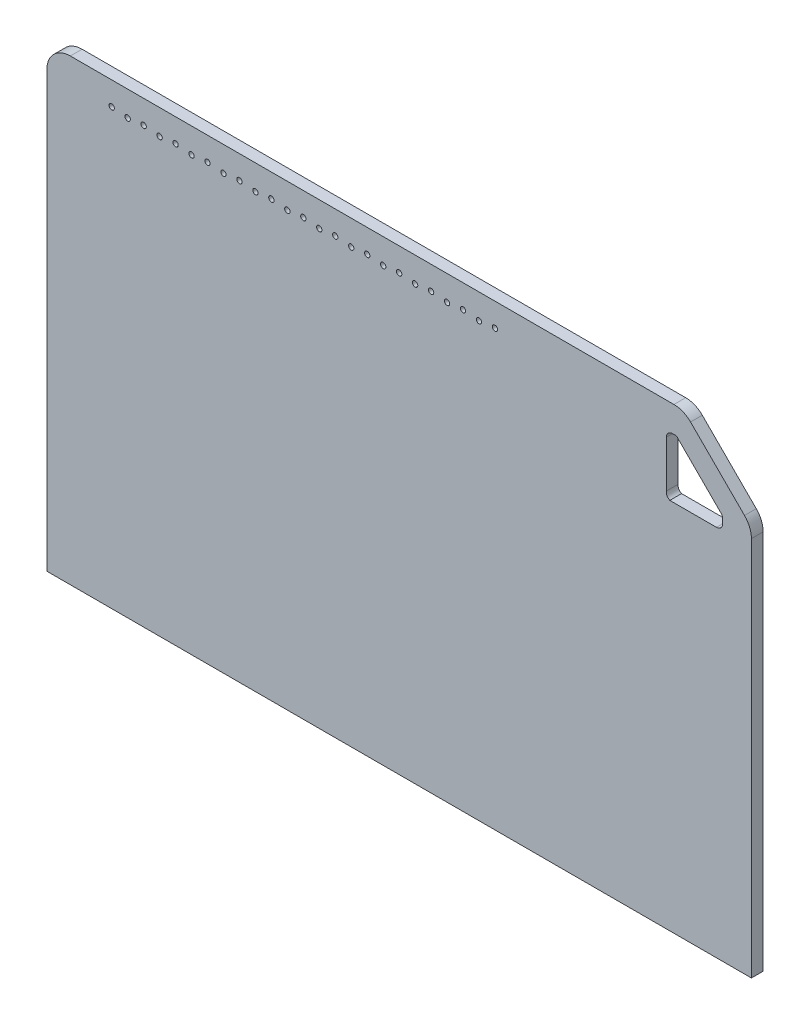
from build123d import *

# Parameters (mm, degrees)
LOWER_MPCHIP_R      = 12.7
BOSS_EXTRUDE1_DEPTH = 25.4
BOSS_EXTRUDE2_DEPTH = 25.4
CUT_EXTRUDE1_DEPTH  = 12.7
SKETCH12_R          = 5.78
CUT_EXTRUDE2_DEPTH  = 26.4
SKETCH13_W          = 3566.23722931
SKETCH13_H          = 1219.2
CUT_EXTRUDE3_DEPTH  = 26.4


with BuildPart() as part:
    # lower mpchip → Boss-Extrude1 (new body)
    with BuildSketch(Plane.XY):
        with BuildLine():
            Line((-762.201152263, -317.508408711), (761.798847737, -317.508408711))
            Line((761.798847737, -317.508408711), (761.798847737, -1480.956188545))
            ThreePointArc((761.798847737, -1480.956188545), (746.752491854, -1519.103697906), (709.716030721, -1536.708408711))
            Line((709.716030721, -1536.708408711), (-486.894749236, -1536.708408711))
            ThreePointArc((-486.894749236, -1536.708408711), (-506.3350676, -1532.841488963), (-522.815773721, -1521.829433195))
            Line((-522.815773721, -1521.829433195), (-747.322176747, -1297.323030169))
            ThreePointArc((-747.322176747, -1297.323030169), (-758.334232515, -1280.842324049), (-762.201152263, -1261.402005684))
            Line((-762.201152263, -1261.402005684), (-762.201152263, -573.5936))
            Line((-762.201152263, -573.5936), (-762.201152263, -317.508408711))
        make_face()
        with Locations((-621.20176, -630.088)):
            Circle(LOWER_MPCHIP_R, mode=Mode.SUBTRACT)
        with Locations((-414.14176, -630.088)):
            Circle(LOWER_MPCHIP_R, mode=Mode.SUBTRACT)
        with Locations((-208.08, -656.064)):
            Circle(LOWER_MPCHIP_R, mode=Mode.SUBTRACT)
        with Locations((-70.04, -656.064)):
            Circle(LOWER_MPCHIP_R, mode=Mode.SUBTRACT)
        with Locations((68, -656.064)):
            Circle(LOWER_MPCHIP_R, mode=Mode.SUBTRACT)
        with Locations((206.04, -656.064)):
            Circle(LOWER_MPCHIP_R, mode=Mode.SUBTRACT)
        with Locations((344.08, -656.064)):
            Circle(LOWER_MPCHIP_R, mode=Mode.SUBTRACT)
        with Locations((482.12, -656.064)):
            Circle(LOWER_MPCHIP_R, mode=Mode.SUBTRACT)
        with Locations((632.264, -656.064)):
            Circle(LOWER_MPCHIP_R, mode=Mode.SUBTRACT)
        with Locations((552.13824, -768.944)):
            Circle(LOWER_MPCHIP_R, mode=Mode.SUBTRACT)
        with Locations((414.09824, -768.944)):
            Circle(LOWER_MPCHIP_R, mode=Mode.SUBTRACT)
        with Locations((276.05824, -768.944)):
            Circle(LOWER_MPCHIP_R, mode=Mode.SUBTRACT)
        with Locations((138.01824, -768.944)):
            Circle(LOWER_MPCHIP_R, mode=Mode.SUBTRACT)
        with Locations((-0.02176, -768.944)):
            Circle(LOWER_MPCHIP_R, mode=Mode.SUBTRACT)
        with Locations((-138.06176, -768.944)):
            Circle(LOWER_MPCHIP_R, mode=Mode.SUBTRACT)
        with Locations((-331.99776, -712.232)):
            Circle(LOWER_MPCHIP_R, mode=Mode.SUBTRACT)
        with Locations((-414.14176, -794.376)):
            Circle(LOWER_MPCHIP_R, mode=Mode.SUBTRACT)
        with Locations((-496.28576, -712.232)):
            Circle(LOWER_MPCHIP_R, mode=Mode.SUBTRACT)
        with Locations((-621.20176, -909.16)):
            Circle(LOWER_MPCHIP_R, mode=Mode.SUBTRACT)
        with Locations((-483.16176, -909.16)):
            Circle(LOWER_MPCHIP_R, mode=Mode.SUBTRACT)
        with Locations((-345.12176, -909.16)):
            Circle(LOWER_MPCHIP_R, mode=Mode.SUBTRACT)
        with Locations((-207.08176, -909.16)):
            Circle(LOWER_MPCHIP_R, mode=Mode.SUBTRACT)
        with Locations((-69.04176, -909.16)):
            Circle(LOWER_MPCHIP_R, mode=Mode.SUBTRACT)
        with Locations((68.99824, -909.16)):
            Circle(LOWER_MPCHIP_R, mode=Mode.SUBTRACT)
        with Locations((207.03824, -909.16)):
            Circle(LOWER_MPCHIP_R, mode=Mode.SUBTRACT)
        with Locations((345.07824, -909.16)):
            Circle(LOWER_MPCHIP_R, mode=Mode.SUBTRACT)
        with Locations((483.11824, -909.16)):
            Circle(LOWER_MPCHIP_R, mode=Mode.SUBTRACT)
        with Locations((621.20176, -909.16)):
            Circle(LOWER_MPCHIP_R, mode=Mode.SUBTRACT)
        with Locations((552.20624, -1022.04)):
            Circle(LOWER_MPCHIP_R, mode=Mode.SUBTRACT)
        with Locations((632.264, -1134.92)):
            Circle(LOWER_MPCHIP_R, mode=Mode.SUBTRACT)
        with Locations((483.11824, -1134.92)):
            Circle(LOWER_MPCHIP_R, mode=Mode.SUBTRACT)
        with Locations((414.16624, -1022.04)):
            Circle(LOWER_MPCHIP_R, mode=Mode.SUBTRACT)
        with Locations((276.12624, -1022.04)):
            Circle(LOWER_MPCHIP_R, mode=Mode.SUBTRACT)
        with Locations((138.08624, -1022.04)):
            Circle(LOWER_MPCHIP_R, mode=Mode.SUBTRACT)
        with Locations((-0.04624, -1022.04)):
            Circle(LOWER_MPCHIP_R, mode=Mode.SUBTRACT)
        with Locations((-137.99376, -1022.04)):
            Circle(LOWER_MPCHIP_R, mode=Mode.SUBTRACT)
        with Locations((-276.03376, -1022.04)):
            Circle(LOWER_MPCHIP_R, mode=Mode.SUBTRACT)
        with Locations((-414.07376, -1022.04)):
            Circle(LOWER_MPCHIP_R, mode=Mode.SUBTRACT)
        with Locations((-552.11376, -1022.04)):
            Circle(LOWER_MPCHIP_R, mode=Mode.SUBTRACT)
        with Locations((-621.20176, -1134.92)):
            Circle(LOWER_MPCHIP_R, mode=Mode.SUBTRACT)
        with Locations((-483.16176, -1134.92)):
            Circle(LOWER_MPCHIP_R, mode=Mode.SUBTRACT)
        with Locations((-345.12176, -1134.92)):
            Circle(LOWER_MPCHIP_R, mode=Mode.SUBTRACT)
        with Locations((-207.08176, -1134.92)):
            Circle(LOWER_MPCHIP_R, mode=Mode.SUBTRACT)
        with Locations((-69.04176, -1134.92)):
            Circle(LOWER_MPCHIP_R, mode=Mode.SUBTRACT)
        with Locations((68.99824, -1134.92)):
            Circle(LOWER_MPCHIP_R, mode=Mode.SUBTRACT)
        with Locations((207.03824, -1134.92)):
            Circle(LOWER_MPCHIP_R, mode=Mode.SUBTRACT)
        with Locations((345.07824, -1134.92)):
            Circle(LOWER_MPCHIP_R, mode=Mode.SUBTRACT)
        with Locations((552.11376, -1247.8)):
            Circle(LOWER_MPCHIP_R, mode=Mode.SUBTRACT)
        with Locations((414.07376, -1247.8)):
            Circle(LOWER_MPCHIP_R, mode=Mode.SUBTRACT)
        with Locations((276.03376, -1247.8)):
            Circle(LOWER_MPCHIP_R, mode=Mode.SUBTRACT)
        with Locations((-276.03376, -1247.8)):
            Circle(LOWER_MPCHIP_R, mode=Mode.SUBTRACT)
        with Locations((-414.07376, -1247.8)):
            Circle(LOWER_MPCHIP_R, mode=Mode.SUBTRACT)
        with Locations((-552.11376, -1247.8)):
            Circle(LOWER_MPCHIP_R, mode=Mode.SUBTRACT)
        with Locations((-97.632449909, -1263.063884579)):
            Circle(LOWER_MPCHIP_R, mode=Mode.SUBTRACT)
        with Locations((106.666799165, -1262.352)):
            Circle(LOWER_MPCHIP_R, mode=Mode.SUBTRACT)
        with Locations((0.272, -1404.472)):
            Circle(LOWER_MPCHIP_R, mode=Mode.SUBTRACT)
        with BuildLine():
            Line((-538.8864, -1379.4208), (-538.8864, -1386.3296))
            ThreePointArc((-538.8864, -1386.3296), (-483.616, -1441.6), (-428.3456, -1386.3296))
            Line((-428.3456, -1386.3296), (-428.3456, -1379.4208))
            ThreePointArc((-428.3456, -1379.4208), (-483.616, -1324.1504), (-538.8864, -1379.4208))
        make_face(mode=Mode.SUBTRACT)
        Polygon((452.208145356, -1437.2752), (515.023854644, -1437.2752), (546.431709288, -1382.8752), (515.023854644, -1328.4752), (452.208145356, -1328.4752), (420.800290712, -1382.8752), align=None, mode=Mode.SUBTRACT)
    extrude(amount=BOSS_EXTRUDE1_DEPTH)

    # Sketch5 → Boss-Extrude2 (add)
    with BuildSketch(Plane.XY):
        with BuildLine():
            Line((761.798847737, -317.508408711), (-762.201152263, -317.508408711))
            Line((-762.201152263, -317.508408711), (-762.201152263, 622.324930397))
            ThreePointArc((-762.201152263, 622.324930397), (-747.322176747, 658.245954881), (-711.401152263, 673.124930397))
            Line((-711.401152263, 673.124930397), (594.255518163, 673.124930397))
            ThreePointArc((594.255518163, 673.124930397), (613.695836527, 669.258010649), (630.176542647, 658.245954881))
            Line((630.176542647, 658.245954881), (746.919872221, 541.502625308))
            ThreePointArc((746.919872221, 541.502625308), (757.931927989, 525.021919187), (761.798847737, 505.581600823))
            Line((761.798847737, 505.581600823), (761.798847737, 68.063364259))
            Line((761.798847737, 68.063364259), (761.798847737, -317.508408711))
        make_face()
        with BuildLine():
            Line((585.298918243, 488.974930397), (686.183718243, 488.974930397))
            ThreePointArc((686.183718243, 488.974930397), (695.800370467, 492.958278173), (699.783718243, 502.574930397))
            Line((699.783718243, 502.574930397), (699.783718243, 510.541625949))
            ThreePointArc((699.783718243, 510.541625949), (698.895409188, 516.020679535), (695.891961756, 520.688486804))
            Line((695.891961756, 520.688486804), (602.973857308, 613.606591252))
            ThreePointArc((602.973857308, 613.606591252), (601.251852502, 615.463066183), (599.215543289, 616.968139108))
            Line((599.215543289, 616.968139108), (591.248847737, 616.968139108))
            ThreePointArc((591.248847737, 616.968139108), (581.632195513, 612.984791332), (577.648847737, 603.368139108))
            Line((577.648847737, 603.368139108), (577.648847737, 502.483339108))
            ThreePointArc((577.648847737, 502.483339108), (579.357112847, 494.53036729), (585.298918243, 488.974930397))
        make_face(mode=Mode.SUBTRACT)
    extrude(amount=BOSS_EXTRUDE2_DEPTH)

    # Sketch6 → Cut-Extrude1 (cut)
    with BuildSketch(Plane.XY.offset(25.4)):
        with BuildLine():
            ThreePointArc((4.331497575, -1447.460752941), (43.452, -1404.472), (4.331497575, -1361.483247059))
            ThreePointArc((4.331497575, -1361.483247059), (0.272, -1357.228), (-3.787497575, -1361.483247059))
            ThreePointArc((-3.787497575, -1361.483247059), (-42.908, -1404.472), (-3.787497575, -1447.460752941))
            ThreePointArc((-3.787497575, -1447.460752941), (0.272, -1451.716), (4.331497575, -1447.460752941))
        make_face()
        with BuildLine():
            ThreePointArc((110.72629674, -1305.340752941), (149.846799165, -1262.352), (110.72629674, -1219.363247059))
            ThreePointArc((110.72629674, -1219.363247059), (106.666799165, -1215.108), (102.60730159, -1219.363247059))
            ThreePointArc((102.60730159, -1219.363247059), (63.486799165, -1262.352), (102.60730159, -1305.340752941))
            ThreePointArc((102.60730159, -1305.340752941), (106.666799165, -1309.596), (110.72629674, -1305.340752941))
        make_face()
        with BuildLine():
            ThreePointArc((280.093257575, -1290.788752941), (319.21376, -1247.8), (280.093257575, -1204.811247059))
            ThreePointArc((280.093257575, -1204.811247059), (276.03376, -1200.556), (271.974262425, -1204.811247059))
            ThreePointArc((271.974262425, -1204.811247059), (232.85376, -1247.8), (271.974262425, -1290.788752941))
            ThreePointArc((271.974262425, -1290.788752941), (276.03376, -1295.044), (280.093257575, -1290.788752941))
        make_face()
        with BuildLine():
            ThreePointArc((-93.572952334, -1306.05263752), (-54.452449909, -1263.063884579), (-93.572952334, -1220.075131637))
            ThreePointArc((-93.572952334, -1220.075131637), (-97.632449909, -1215.819884579), (-101.691947484, -1220.075131637))
            ThreePointArc((-101.691947484, -1220.075131637), (-140.812449909, -1263.063884579), (-101.691947484, -1306.05263752))
            ThreePointArc((-101.691947484, -1306.05263752), (-97.632449909, -1310.307884579), (-93.572952334, -1306.05263752))
        make_face()
        with BuildLine():
            ThreePointArc((-271.974262425, -1290.788752941), (-232.85376, -1247.8), (-271.974262425, -1204.811247059))
            ThreePointArc((-271.974262425, -1204.811247059), (-276.03376, -1200.556), (-280.093257575, -1204.811247059))
            ThreePointArc((-280.093257575, -1204.811247059), (-319.21376, -1247.8), (-280.093257575, -1290.788752941))
            ThreePointArc((-280.093257575, -1290.788752941), (-276.03376, -1295.044), (-271.974262425, -1290.788752941))
        make_face()
        with BuildLine():
            ThreePointArc((-410.014262425, -1290.788752941), (-370.89376, -1247.8), (-410.014262425, -1204.811247059))
            ThreePointArc((-410.014262425, -1204.811247059), (-414.07376, -1200.556), (-418.133257575, -1204.811247059))
            ThreePointArc((-418.133257575, -1204.811247059), (-457.25376, -1247.8), (-418.133257575, -1290.788752941))
            ThreePointArc((-418.133257575, -1290.788752941), (-414.07376, -1295.044), (-410.014262425, -1290.788752941))
        make_face()
        with BuildLine():
            ThreePointArc((-341.062262425, -1177.908752941), (-301.94176, -1134.92), (-341.062262425, -1091.931247059))
            ThreePointArc((-341.062262425, -1091.931247059), (-345.12176, -1087.676), (-349.181257575, -1091.931247059))
            ThreePointArc((-349.181257575, -1091.931247059), (-388.30176, -1134.92), (-349.181257575, -1177.908752941))
            ThreePointArc((-349.181257575, -1177.908752941), (-345.12176, -1182.164), (-341.062262425, -1177.908752941))
        make_face()
        with BuildLine():
            ThreePointArc((-203.022262425, -1177.908752941), (-163.90176, -1134.92), (-203.022262425, -1091.931247059))
            ThreePointArc((-203.022262425, -1091.931247059), (-207.08176, -1087.676), (-211.141257575, -1091.931247059))
            ThreePointArc((-211.141257575, -1091.931247059), (-250.26176, -1134.92), (-211.141257575, -1177.908752941))
            ThreePointArc((-211.141257575, -1177.908752941), (-207.08176, -1182.164), (-203.022262425, -1177.908752941))
        make_face()
        with BuildLine():
            ThreePointArc((-64.982262425, -1177.908752941), (-25.86176, -1134.92), (-64.982262425, -1091.931247059))
            ThreePointArc((-64.982262425, -1091.931247059), (-69.04176, -1087.676), (-73.101257575, -1091.931247059))
            ThreePointArc((-73.101257575, -1091.931247059), (-112.22176, -1134.92), (-73.101257575, -1177.908752941))
            ThreePointArc((-73.101257575, -1177.908752941), (-69.04176, -1182.164), (-64.982262425, -1177.908752941))
        make_face()
        with BuildLine():
            ThreePointArc((73.057737575, -1177.908752941), (112.17824, -1134.92), (73.057737575, -1091.931247059))
            ThreePointArc((73.057737575, -1091.931247059), (68.99824, -1087.676), (64.938742425, -1091.931247059))
            ThreePointArc((64.938742425, -1091.931247059), (25.81824, -1134.92), (64.938742425, -1177.908752941))
            ThreePointArc((64.938742425, -1177.908752941), (68.99824, -1182.164), (73.057737575, -1177.908752941))
        make_face()
        with BuildLine():
            ThreePointArc((211.097737575, -1177.908752941), (250.21824, -1134.92), (211.097737575, -1091.931247059))
            ThreePointArc((211.097737575, -1091.931247059), (207.03824, -1087.676), (202.978742425, -1091.931247059))
            ThreePointArc((202.978742425, -1091.931247059), (163.85824, -1134.92), (202.978742425, -1177.908752941))
            ThreePointArc((202.978742425, -1177.908752941), (207.03824, -1182.164), (211.097737575, -1177.908752941))
        make_face()
        with BuildLine():
            ThreePointArc((349.137737575, -1177.908752941), (388.25824, -1134.92), (349.137737575, -1091.931247059))
            ThreePointArc((349.137737575, -1091.931247059), (345.07824, -1087.676), (341.018742425, -1091.931247059))
            ThreePointArc((341.018742425, -1091.931247059), (301.89824, -1134.92), (341.018742425, -1177.908752941))
            ThreePointArc((341.018742425, -1177.908752941), (345.07824, -1182.164), (349.137737575, -1177.908752941))
        make_face()
        with BuildLine():
            ThreePointArc((487.177737575, -1177.908752941), (526.29824, -1134.92), (487.177737575, -1091.931247059))
            ThreePointArc((487.177737575, -1091.931247059), (483.11824, -1087.676), (479.058742425, -1091.931247059))
            ThreePointArc((479.058742425, -1091.931247059), (439.93824, -1134.92), (479.058742425, -1177.908752941))
            ThreePointArc((479.058742425, -1177.908752941), (483.11824, -1182.164), (487.177737575, -1177.908752941))
        make_face()
        with BuildLine():
            ThreePointArc((636.323497575, -1177.908752941), (675.444, -1134.92), (636.323497575, -1091.931247059))
            ThreePointArc((636.323497575, -1091.931247059), (632.264, -1087.676), (628.204502425, -1091.931247059))
            ThreePointArc((628.204502425, -1091.931247059), (589.084, -1134.92), (628.204502425, -1177.908752941))
            ThreePointArc((628.204502425, -1177.908752941), (632.264, -1182.164), (636.323497575, -1177.908752941))
        make_face()
        with BuildLine():
            ThreePointArc((556.173257575, -1290.788752941), (595.29376, -1247.8), (556.173257575, -1204.811247059))
            ThreePointArc((556.173257575, -1204.811247059), (552.11376, -1200.556), (548.054262425, -1204.811247059))
            ThreePointArc((548.054262425, -1204.811247059), (508.93376, -1247.8), (548.054262425, -1290.788752941))
            ThreePointArc((548.054262425, -1290.788752941), (552.11376, -1295.044), (556.173257575, -1290.788752941))
        make_face()
        with BuildLine():
            ThreePointArc((418.133257575, -1290.788752941), (457.25376, -1247.8), (418.133257575, -1204.811247059))
            ThreePointArc((418.133257575, -1204.811247059), (414.07376, -1200.556), (410.014262425, -1204.811247059))
            ThreePointArc((410.014262425, -1204.811247059), (370.89376, -1247.8), (410.014262425, -1290.788752941))
            ThreePointArc((410.014262425, -1290.788752941), (414.07376, -1295.044), (418.133257575, -1290.788752941))
        make_face()
        with BuildLine():
            ThreePointArc((418.225737575, -1065.028752941), (457.34624, -1022.04), (418.225737575, -979.051247059))
            ThreePointArc((418.225737575, -979.051247059), (414.16624, -974.796), (410.106742425, -979.051247059))
            ThreePointArc((410.106742425, -979.051247059), (370.98624, -1022.04), (410.106742425, -1065.028752941))
            ThreePointArc((410.106742425, -1065.028752941), (414.16624, -1069.284), (418.225737575, -1065.028752941))
        make_face()
        with BuildLine():
            ThreePointArc((556.265737575, -1065.028752941), (595.38624, -1022.04), (556.265737575, -979.051247059))
            ThreePointArc((556.265737575, -979.051247059), (552.20624, -974.796), (548.146742425, -979.051247059))
            ThreePointArc((548.146742425, -979.051247059), (509.02624, -1022.04), (548.146742425, -1065.028752941))
            ThreePointArc((548.146742425, -1065.028752941), (552.20624, -1069.284), (556.265737575, -1065.028752941))
        make_face()
        with BuildLine():
            ThreePointArc((280.185737575, -1065.028752941), (319.30624, -1022.04), (280.185737575, -979.051247059))
            ThreePointArc((280.185737575, -979.051247059), (276.12624, -974.796), (272.066742425, -979.051247059))
            ThreePointArc((272.066742425, -979.051247059), (232.94624, -1022.04), (272.066742425, -1065.028752941))
            ThreePointArc((272.066742425, -1065.028752941), (276.12624, -1069.284), (280.185737575, -1065.028752941))
        make_face()
        with BuildLine():
            ThreePointArc((142.145737575, -1065.028752941), (181.26624, -1022.04), (142.145737575, -979.051247059))
            ThreePointArc((142.145737575, -979.051247059), (138.08624, -974.796), (134.026742425, -979.051247059))
            ThreePointArc((134.026742425, -979.051247059), (94.90624, -1022.04), (134.026742425, -1065.028752941))
            ThreePointArc((134.026742425, -1065.028752941), (138.08624, -1069.284), (142.145737575, -1065.028752941))
        make_face()
        with BuildLine():
            ThreePointArc((4.013257575, -1065.028752941), (43.13376, -1022.04), (4.013257575, -979.051247059))
            ThreePointArc((4.013257575, -979.051247059), (-0.04624, -974.796), (-4.105737575, -979.051247059))
            ThreePointArc((-4.105737575, -979.051247059), (-43.22624, -1022.04), (-4.105737575, -1065.028752941))
            ThreePointArc((-4.105737575, -1065.028752941), (-0.04624, -1069.284), (4.013257575, -1065.028752941))
        make_face()
        with BuildLine():
            ThreePointArc((-133.934262425, -1065.028752941), (-94.81376, -1022.04), (-133.934262425, -979.051247059))
            ThreePointArc((-133.934262425, -979.051247059), (-137.99376, -974.796), (-142.053257575, -979.051247059))
            ThreePointArc((-142.053257575, -979.051247059), (-181.17376, -1022.04), (-142.053257575, -1065.028752941))
            ThreePointArc((-142.053257575, -1065.028752941), (-137.99376, -1069.284), (-133.934262425, -1065.028752941))
        make_face()
        with BuildLine():
            ThreePointArc((-271.974262425, -1065.028752941), (-232.85376, -1022.04), (-271.974262425, -979.051247059))
            ThreePointArc((-271.974262425, -979.051247059), (-276.03376, -974.796), (-280.093257575, -979.051247059))
            ThreePointArc((-280.093257575, -979.051247059), (-319.21376, -1022.04), (-280.093257575, -1065.028752941))
            ThreePointArc((-280.093257575, -1065.028752941), (-276.03376, -1069.284), (-271.974262425, -1065.028752941))
        make_face()
        with BuildLine():
            ThreePointArc((-410.014262425, -1065.028752941), (-370.89376, -1022.04), (-410.014262425, -979.051247059))
            ThreePointArc((-410.014262425, -979.051247059), (-414.07376, -974.796), (-418.133257575, -979.051247059))
            ThreePointArc((-418.133257575, -979.051247059), (-457.25376, -1022.04), (-418.133257575, -1065.028752941))
            ThreePointArc((-418.133257575, -1065.028752941), (-414.07376, -1069.284), (-410.014262425, -1065.028752941))
        make_face()
        with BuildLine():
            ThreePointArc((-548.054262425, -1065.028752941), (-508.93376, -1022.04), (-548.054262425, -979.051247059))
            ThreePointArc((-548.054262425, -979.051247059), (-552.11376, -974.796), (-556.173257575, -979.051247059))
            ThreePointArc((-556.173257575, -979.051247059), (-595.29376, -1022.04), (-556.173257575, -1065.028752941))
            ThreePointArc((-556.173257575, -1065.028752941), (-552.11376, -1069.284), (-548.054262425, -1065.028752941))
        make_face()
        with BuildLine():
            ThreePointArc((-617.142262425, -1177.908752941), (-578.02176, -1134.92), (-617.142262425, -1091.931247059))
            ThreePointArc((-617.142262425, -1091.931247059), (-621.20176, -1087.676), (-625.261257575, -1091.931247059))
            ThreePointArc((-625.261257575, -1091.931247059), (-664.38176, -1134.92), (-625.261257575, -1177.908752941))
            ThreePointArc((-625.261257575, -1177.908752941), (-621.20176, -1182.164), (-617.142262425, -1177.908752941))
        make_face()
        with BuildLine():
            ThreePointArc((-479.102262425, -1177.908752941), (-439.98176, -1134.92), (-479.102262425, -1091.931247059))
            ThreePointArc((-479.102262425, -1091.931247059), (-483.16176, -1087.676), (-487.221257575, -1091.931247059))
            ThreePointArc((-487.221257575, -1091.931247059), (-526.34176, -1134.92), (-487.221257575, -1177.908752941))
            ThreePointArc((-487.221257575, -1177.908752941), (-483.16176, -1182.164), (-479.102262425, -1177.908752941))
        make_face()
        with BuildLine():
            ThreePointArc((-548.054262425, -1290.788752941), (-508.93376, -1247.8), (-548.054262425, -1204.811247059))
            ThreePointArc((-548.054262425, -1204.811247059), (-552.11376, -1200.556), (-556.173257575, -1204.811247059))
            ThreePointArc((-556.173257575, -1204.811247059), (-595.29376, -1247.8), (-556.173257575, -1290.788752941))
            ThreePointArc((-556.173257575, -1290.788752941), (-552.11376, -1295.044), (-548.054262425, -1290.788752941))
        make_face()
        with BuildLine():
            ThreePointArc((-617.142262425, -952.148752941), (-578.02176, -909.16), (-617.142262425, -866.171247059))
            ThreePointArc((-617.142262425, -866.171247059), (-621.20176, -861.916), (-625.261257575, -866.171247059))
            ThreePointArc((-625.261257575, -866.171247059), (-664.38176, -909.16), (-625.261257575, -952.148752941))
            ThreePointArc((-625.261257575, -952.148752941), (-621.20176, -956.404), (-617.142262425, -952.148752941))
        make_face()
        with BuildLine():
            ThreePointArc((-479.102262425, -952.148752941), (-439.98176, -909.16), (-479.102262425, -866.171247059))
            ThreePointArc((-479.102262425, -866.171247059), (-483.16176, -861.916), (-487.221257575, -866.171247059))
            ThreePointArc((-487.221257575, -866.171247059), (-526.34176, -909.16), (-487.221257575, -952.148752941))
            ThreePointArc((-487.221257575, -952.148752941), (-483.16176, -956.404), (-479.102262425, -952.148752941))
        make_face()
        with BuildLine():
            ThreePointArc((-341.062262425, -952.148752941), (-301.94176, -909.16), (-341.062262425, -866.171247059))
            ThreePointArc((-341.062262425, -866.171247059), (-345.12176, -861.916), (-349.181257575, -866.171247059))
            ThreePointArc((-349.181257575, -866.171247059), (-388.30176, -909.16), (-349.181257575, -952.148752941))
            ThreePointArc((-349.181257575, -952.148752941), (-345.12176, -956.404), (-341.062262425, -952.148752941))
        make_face()
        with BuildLine():
            ThreePointArc((-203.022262425, -952.148752941), (-163.90176, -909.16), (-203.022262425, -866.171247059))
            ThreePointArc((-203.022262425, -866.171247059), (-207.08176, -861.916), (-211.141257575, -866.171247059))
            ThreePointArc((-211.141257575, -866.171247059), (-250.26176, -909.16), (-211.141257575, -952.148752941))
            ThreePointArc((-211.141257575, -952.148752941), (-207.08176, -956.404), (-203.022262425, -952.148752941))
        make_face()
        with BuildLine():
            ThreePointArc((-64.982262425, -952.148752941), (-25.86176, -909.16), (-64.982262425, -866.171247059))
            ThreePointArc((-64.982262425, -866.171247059), (-69.04176, -861.916), (-73.101257575, -866.171247059))
            ThreePointArc((-73.101257575, -866.171247059), (-112.22176, -909.16), (-73.101257575, -952.148752941))
            ThreePointArc((-73.101257575, -952.148752941), (-69.04176, -956.404), (-64.982262425, -952.148752941))
        make_face()
        with BuildLine():
            ThreePointArc((73.057737575, -952.148752941), (112.17824, -909.16), (73.057737575, -866.171247059))
            ThreePointArc((73.057737575, -866.171247059), (68.99824, -861.916), (64.938742425, -866.171247059))
            ThreePointArc((64.938742425, -866.171247059), (25.81824, -909.16), (64.938742425, -952.148752941))
            ThreePointArc((64.938742425, -952.148752941), (68.99824, -956.404), (73.057737575, -952.148752941))
        make_face()
        with BuildLine():
            ThreePointArc((211.097737575, -952.148752941), (250.21824, -909.16), (211.097737575, -866.171247059))
            ThreePointArc((211.097737575, -866.171247059), (207.03824, -861.916), (202.978742425, -866.171247059))
            ThreePointArc((202.978742425, -866.171247059), (163.85824, -909.16), (202.978742425, -952.148752941))
            ThreePointArc((202.978742425, -952.148752941), (207.03824, -956.404), (211.097737575, -952.148752941))
        make_face()
        with BuildLine():
            ThreePointArc((349.137737575, -952.148752941), (388.25824, -909.16), (349.137737575, -866.171247059))
            ThreePointArc((349.137737575, -866.171247059), (345.07824, -861.916), (341.018742425, -866.171247059))
            ThreePointArc((341.018742425, -866.171247059), (301.89824, -909.16), (341.018742425, -952.148752941))
            ThreePointArc((341.018742425, -952.148752941), (345.07824, -956.404), (349.137737575, -952.148752941))
        make_face()
        with BuildLine():
            ThreePointArc((487.177737575, -952.148752941), (526.29824, -909.16), (487.177737575, -866.171247059))
            ThreePointArc((487.177737575, -866.171247059), (483.11824, -861.916), (479.058742425, -866.171247059))
            ThreePointArc((479.058742425, -866.171247059), (439.93824, -909.16), (479.058742425, -952.148752941))
            ThreePointArc((479.058742425, -952.148752941), (483.11824, -956.404), (487.177737575, -952.148752941))
        make_face()
        with BuildLine():
            ThreePointArc((625.261257575, -952.148752941), (664.38176, -909.16), (625.261257575, -866.171247059))
            ThreePointArc((625.261257575, -866.171247059), (621.20176, -861.916), (617.142262425, -866.171247059))
            ThreePointArc((617.142262425, -866.171247059), (578.02176, -909.16), (617.142262425, -952.148752941))
            ThreePointArc((617.142262425, -952.148752941), (621.20176, -956.404), (625.261257575, -952.148752941))
        make_face()
        with BuildLine():
            ThreePointArc((-410.082262425, -837.364752941), (-370.96176, -794.376), (-410.082262425, -751.387247059))
            ThreePointArc((-410.082262425, -751.387247059), (-414.14176, -747.132), (-418.201257575, -751.387247059))
            ThreePointArc((-418.201257575, -751.387247059), (-457.32176, -794.376), (-418.201257575, -837.364752941))
            ThreePointArc((-418.201257575, -837.364752941), (-414.14176, -841.62), (-410.082262425, -837.364752941))
        make_face()
        with BuildLine():
            ThreePointArc((-327.938262425, -755.220752941), (-288.81776, -712.232), (-327.938262425, -669.243247059))
            ThreePointArc((-327.938262425, -669.243247059), (-331.99776, -664.988), (-336.057257575, -669.243247059))
            ThreePointArc((-336.057257575, -669.243247059), (-375.17776, -712.232), (-336.057257575, -755.220752941))
            ThreePointArc((-336.057257575, -755.220752941), (-331.99776, -759.476), (-327.938262425, -755.220752941))
        make_face()
        with BuildLine():
            ThreePointArc((-410.082262425, -673.076752941), (-370.96176, -630.088), (-410.082262425, -587.099247059))
            ThreePointArc((-410.082262425, -587.099247059), (-414.14176, -582.844), (-418.201257575, -587.099247059))
            ThreePointArc((-418.201257575, -587.099247059), (-457.32176, -630.088), (-418.201257575, -673.076752941))
            ThreePointArc((-418.201257575, -673.076752941), (-414.14176, -677.332), (-410.082262425, -673.076752941))
        make_face()
        with BuildLine():
            ThreePointArc((-492.226262425, -755.220752941), (-453.10576, -712.232), (-492.226262425, -669.243247059))
            ThreePointArc((-492.226262425, -669.243247059), (-496.28576, -664.988), (-500.345257575, -669.243247059))
            ThreePointArc((-500.345257575, -669.243247059), (-539.46576, -712.232), (-500.345257575, -755.220752941))
            ThreePointArc((-500.345257575, -755.220752941), (-496.28576, -759.476), (-492.226262425, -755.220752941))
        make_face()
        with BuildLine():
            ThreePointArc((-617.142262425, -673.076752941), (-578.02176, -630.088), (-617.142262425, -587.099247059))
            ThreePointArc((-617.142262425, -587.099247059), (-621.20176, -582.844), (-625.261257575, -587.099247059))
            ThreePointArc((-625.261257575, -587.099247059), (-664.38176, -630.088), (-625.261257575, -673.076752941))
            ThreePointArc((-625.261257575, -673.076752941), (-621.20176, -677.332), (-617.142262425, -673.076752941))
        make_face()
        with BuildLine():
            ThreePointArc((-65.980502425, -699.052752941), (-26.86, -656.064), (-65.980502425, -613.075247059))
            ThreePointArc((-65.980502425, -613.075247059), (-70.04, -608.82), (-74.099497575, -613.075247059))
            ThreePointArc((-74.099497575, -613.075247059), (-113.22, -656.064), (-74.099497575, -699.052752941))
            ThreePointArc((-74.099497575, -699.052752941), (-70.04, -703.308), (-65.980502425, -699.052752941))
        make_face()
        with BuildLine():
            ThreePointArc((-204.020502425, -699.052752941), (-164.9, -656.064), (-204.020502425, -613.075247059))
            ThreePointArc((-204.020502425, -613.075247059), (-208.08, -608.82), (-212.139497575, -613.075247059))
            ThreePointArc((-212.139497575, -613.075247059), (-251.26, -656.064), (-212.139497575, -699.052752941))
            ThreePointArc((-212.139497575, -699.052752941), (-208.08, -703.308), (-204.020502425, -699.052752941))
        make_face()
        with BuildLine():
            ThreePointArc((-134.002262425, -811.932752941), (-94.88176, -768.944), (-134.002262425, -725.955247059))
            ThreePointArc((-134.002262425, -725.955247059), (-138.06176, -721.7), (-142.121257575, -725.955247059))
            ThreePointArc((-142.121257575, -725.955247059), (-181.24176, -768.944), (-142.121257575, -811.932752941))
            ThreePointArc((-142.121257575, -811.932752941), (-138.06176, -816.188), (-134.002262425, -811.932752941))
        make_face()
        with BuildLine():
            ThreePointArc((4.037737575, -811.932752941), (43.15824, -768.944), (4.037737575, -725.955247059))
            ThreePointArc((4.037737575, -725.955247059), (-0.02176, -721.7), (-4.081257575, -725.955247059))
            ThreePointArc((-4.081257575, -725.955247059), (-43.20176, -768.944), (-4.081257575, -811.932752941))
            ThreePointArc((-4.081257575, -811.932752941), (-0.02176, -816.188), (4.037737575, -811.932752941))
        make_face()
        with BuildLine():
            ThreePointArc((142.077737575, -811.932752941), (181.19824, -768.944), (142.077737575, -725.955247059))
            ThreePointArc((142.077737575, -725.955247059), (138.01824, -721.7), (133.958742425, -725.955247059))
            ThreePointArc((133.958742425, -725.955247059), (94.83824, -768.944), (133.958742425, -811.932752941))
            ThreePointArc((133.958742425, -811.932752941), (138.01824, -816.188), (142.077737575, -811.932752941))
        make_face()
        with BuildLine():
            ThreePointArc((210.099497575, -699.052752941), (249.22, -656.064), (210.099497575, -613.075247059))
            ThreePointArc((210.099497575, -613.075247059), (206.04, -608.82), (201.980502425, -613.075247059))
            ThreePointArc((201.980502425, -613.075247059), (162.86, -656.064), (201.980502425, -699.052752941))
            ThreePointArc((201.980502425, -699.052752941), (206.04, -703.308), (210.099497575, -699.052752941))
        make_face()
        with BuildLine():
            ThreePointArc((348.139497575, -699.052752941), (387.26, -656.064), (348.139497575, -613.075247059))
            ThreePointArc((348.139497575, -613.075247059), (344.08, -608.82), (340.020502425, -613.075247059))
            ThreePointArc((340.020502425, -613.075247059), (300.9, -656.064), (340.020502425, -699.052752941))
            ThreePointArc((340.020502425, -699.052752941), (344.08, -703.308), (348.139497575, -699.052752941))
        make_face()
        with BuildLine():
            ThreePointArc((280.117737575, -811.932752941), (319.23824, -768.944), (280.117737575, -725.955247059))
            ThreePointArc((280.117737575, -725.955247059), (276.05824, -721.7), (271.998742425, -725.955247059))
            ThreePointArc((271.998742425, -725.955247059), (232.87824, -768.944), (271.998742425, -811.932752941))
            ThreePointArc((271.998742425, -811.932752941), (276.05824, -816.188), (280.117737575, -811.932752941))
        make_face()
        with BuildLine():
            ThreePointArc((418.157737575, -811.932752941), (457.27824, -768.944), (418.157737575, -725.955247059))
            ThreePointArc((418.157737575, -725.955247059), (414.09824, -721.7), (410.038742425, -725.955247059))
            ThreePointArc((410.038742425, -725.955247059), (370.91824, -768.944), (410.038742425, -811.932752941))
            ThreePointArc((410.038742425, -811.932752941), (414.09824, -816.188), (418.157737575, -811.932752941))
        make_face()
        with BuildLine():
            ThreePointArc((556.197737575, -811.932752941), (595.31824, -768.944), (556.197737575, -725.955247059))
            ThreePointArc((556.197737575, -725.955247059), (552.13824, -721.7), (548.078742425, -725.955247059))
            ThreePointArc((548.078742425, -725.955247059), (508.95824, -768.944), (548.078742425, -811.932752941))
            ThreePointArc((548.078742425, -811.932752941), (552.13824, -816.188), (556.197737575, -811.932752941))
        make_face()
        with BuildLine():
            ThreePointArc((636.323497575, -699.052752941), (675.444, -656.064), (636.323497575, -613.075247059))
            ThreePointArc((636.323497575, -613.075247059), (632.264, -608.82), (628.204502425, -613.075247059))
            ThreePointArc((628.204502425, -613.075247059), (589.084, -656.064), (628.204502425, -699.052752941))
            ThreePointArc((628.204502425, -699.052752941), (632.264, -703.308), (636.323497575, -699.052752941))
        make_face()
        with BuildLine():
            ThreePointArc((486.179497575, -699.052752941), (525.3, -656.064), (486.179497575, -613.075247059))
            ThreePointArc((486.179497575, -613.075247059), (482.12, -608.82), (478.060502425, -613.075247059))
            ThreePointArc((478.060502425, -613.075247059), (438.94, -656.064), (478.060502425, -699.052752941))
            ThreePointArc((478.060502425, -699.052752941), (482.12, -703.308), (486.179497575, -699.052752941))
        make_face()
        with BuildLine():
            ThreePointArc((72.059497575, -699.052752941), (111.18, -656.064), (72.059497575, -613.075247059))
            ThreePointArc((72.059497575, -613.075247059), (68, -608.82), (63.940502425, -613.075247059))
            ThreePointArc((63.940502425, -613.075247059), (24.82, -656.064), (63.940502425, -699.052752941))
            ThreePointArc((63.940502425, -699.052752941), (68, -703.308), (72.059497575, -699.052752941))
        make_face()
    extrude(amount=-CUT_EXTRUDE1_DEPTH, mode=Mode.SUBTRACT)

    # Sketch12 → Cut-Extrude2 (cut, through all)
    with BuildSketch(Plane.XY.offset(25.4)):
        with Locations((-311.058943987, 619.02133005)):
            Circle(SKETCH12_R)
        with Locations((-103.794943987, 619.02133005)):
            Circle(SKETCH12_R)
        with Locations((-621.954943987, 622.47573005)):
            Circle(SKETCH12_R)
        with Locations((-0.162943987, 622.47573005)):
            Circle(SKETCH12_R)
        with Locations((-345.602943987, 622.47573005)):
            Circle(SKETCH12_R)
        with Locations((-552.866943987, 622.47573005)):
            Circle(SKETCH12_R)
        with Locations((-483.778943987, 622.47573005)):
            Circle(SKETCH12_R)
        with Locations((-69.250943987, 622.47573005)):
            Circle(SKETCH12_R)
        with Locations((103.469056013, 619.02133005)):
            Circle(SKETCH12_R)
        with Locations((-207.426943987, 622.47573005)):
            Circle(SKETCH12_R)
        with Locations((207.101056013, 622.47573005)):
            Circle(SKETCH12_R)
        with Locations((138.013056013, 622.47573005)):
            Circle(SKETCH12_R)
        with Locations((-414.690943987, 622.47573005)):
            Circle(SKETCH12_R)
        with Locations((34.381056013, 619.02133005)):
            Circle(SKETCH12_R)
        with Locations((-449.234943987, 619.02133005)):
            Circle(SKETCH12_R)
        with Locations((-380.146943987, 619.02133005)):
            Circle(SKETCH12_R)
        with Locations((-241.970943987, 619.02133005)):
            Circle(SKETCH12_R)
        with Locations((-587.410943987, 619.02133005)):
            Circle(SKETCH12_R)
        with Locations((172.557056013, 619.02133005)):
            Circle(SKETCH12_R)
        with Locations((-34.706943987, 619.02133005)):
            Circle(SKETCH12_R)
        with Locations((-138.338943987, 622.47573005)):
            Circle(SKETCH12_R)
        with Locations((-172.882943987, 619.02133005)):
            Circle(SKETCH12_R)
        with Locations((68.925056013, 622.47573005)):
            Circle(SKETCH12_R)
        with Locations((-276.514943987, 622.47573005)):
            Circle(SKETCH12_R)
        with Locations((-518.322943987, 619.02133005)):
            Circle(SKETCH12_R)
    extrude(amount=-CUT_EXTRUDE2_DEPTH, mode=Mode.SUBTRACT)

    # Sketch13 → Cut-Extrude3 (cut, through all)
    with BuildSketch(Plane.XY.offset(25.4)):
        with Locations((-353.589944199, -927.108408711)):
            Rectangle(SKETCH13_W, SKETCH13_H)
    extrude(amount=-CUT_EXTRUDE3_DEPTH, mode=Mode.SUBTRACT)


solid = part.part
